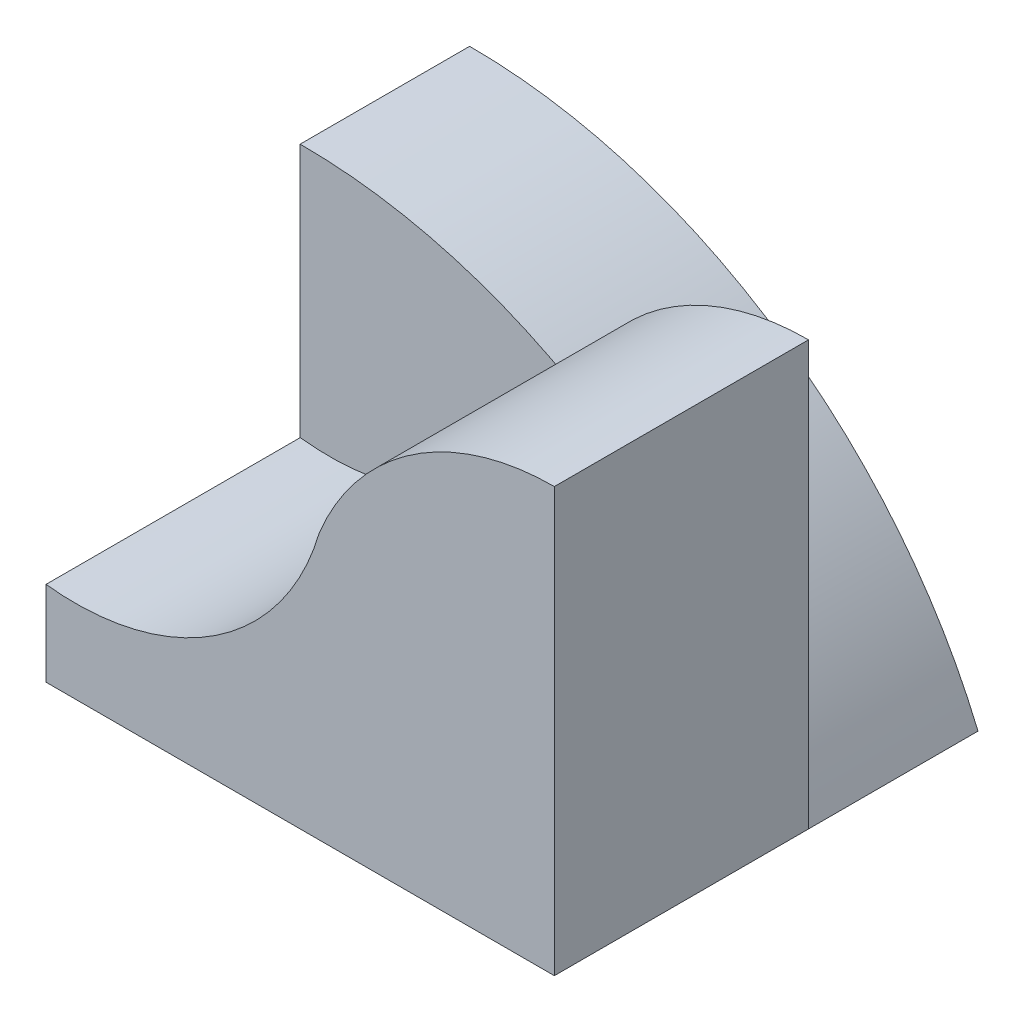
from build123d import *

# Parameters (mm, degrees)
BOSS_EXTRUDE1_DEPTH = 10
BOSS_EXTRUDE5_DEPTH = 15


with BuildPart() as part:
    # Sketch1 → Boss-Extrude1 (new body)
    with BuildSketch(Plane.XY):
        with BuildLine():
            Line((0, 20), (0, 0))
            Line((0, 0), (30, 0))
            ThreePointArc((30, 0), (18.027756377, 14.541634566), (0, 20))
        make_face()
    extrude(amount=BOSS_EXTRUDE1_DEPTH)

    # Sketch2 → Boss-Extrude5 (add)
    with BuildSketch(Plane.XY.offset(10)):
        with BuildLine():
            Line((0, 5), (0, 0))
            Line((0, 0), (30, 0))
            Line((30, 0), (30, 25))
            ThreePointArc((30, 25), (21.654721001, 22.464201476), (16.131034824, 15.71417579))
            ThreePointArc((16.131034824, 15.71417579), (10.026103583, 7.405271123), (0, 5))
        make_face()
    extrude(amount=BOSS_EXTRUDE5_DEPTH)


solid = part.part
